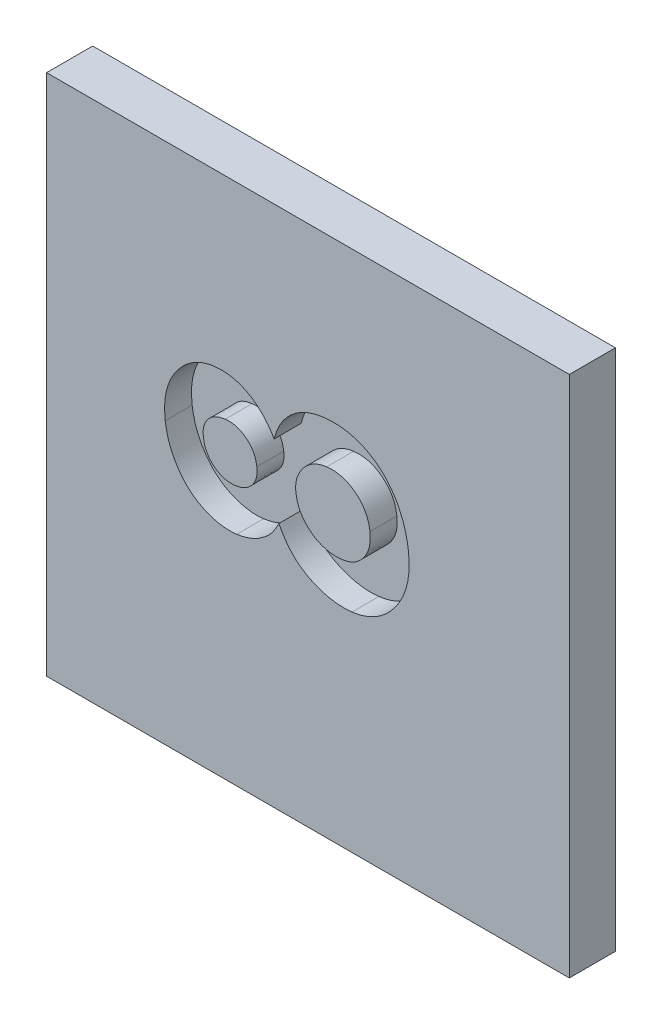
from build123d import *

# Parameters (mm, degrees)
SKIZZE1_W                       = 136
SKIZZE1_H                       = 136
AUFSATZ_LINEAR_AUSTRAGEN1_DEPTH = 12
SCHNITT_LINEAR_AUSTRAGEN2_DEPTH = 7


with BuildPart() as part:
    # Skizze1 → Aufsatz-Linear austragen1 (new body)
    with BuildSketch(Plane.XY):
        with Locations((18, -38)):
            Rectangle(SKIZZE1_W, SKIZZE1_H)
    extrude(amount=AUFSATZ_LINEAR_AUSTRAGEN1_DEPTH)

    # Skizze2 → Schnitt-Linear austragen2 (cut)
    with BuildSketch(Plane(origin=(31.817178146, 33.536064215, 12), x_dir=(-0.121869343, 0.992546152, 0), z_dir=(0, 0, 1))):
        with BuildLine():
            add(Edge.make_bspline(
                [(-53.274003062, 29.299786841), (-52.549854037, 28.997029862), (-51.129325688, 28.403126042), (-49.217358679, 27.153857855), (-47.540898563, 25.676342761), (-46.383253592, 24.230129356), (-45.579392411, 22.986547621), (-45.060203572, 21.996870887), (-44.632569988, 20.959918203), (-44.264434, 19.886493576), (-43.993212362, 18.762770223), (-43.787214797, 17.599258828), (-43.663882177, 16.389802125), (-43.652426375, 15.570103704), (-43.646599216, 15.153152225)],
                knots=[0, 0, 0, 0, 1.541464985, 3.0238178, 4.469784276, 5.921154489, 6.651437481, 7.38125241, 8.116115087, 8.856410813, 9.611538438, 10.387763072, 11.179912327, 12, 12, 12, 12], degree=3))
            add(Edge.make_bspline(
                [(-43.646599216, 15.153152225), (-43.650934028, 14.691984843), (-43.659509441, 13.779673016), (-43.806624249, 12.42868072), (-43.996415085, 11.108137934), (-44.308124238, 9.830927438), (-44.67636284, 8.587963111), (-45.135088006, 7.377098838), (-45.689116874, 6.208146216), (-46.311698148, 5.070923482), (-47.023881325, 3.99679881), (-47.791091102, 2.963169428), (-48.649851657, 2.008814583), (-49.564217558, 1.095396539), (-50.565090055, 0.262097691), (-51.626733483, -0.529779066), (-52.769329329, -1.242961105), (-53.9700016, -1.907524654), (-55.227178587, -2.493269476), (-56.533265143, -2.999356359), (-57.882028006, -3.431682546), (-59.277289658, -3.794809881), (-60.718920323, -4.070090999), (-62.204444332, -4.257904021), (-63.72850672, -4.385263221), (-64.760116786, -4.396473554), (-65.2812146, -4.402136236)],
                knots=[0, 0, 0, 0, 1.013897126, 2.005758377, 2.986752608, 3.946615008, 4.894629566, 5.837467942, 6.791608008, 7.738392708, 8.686857814, 9.624615693, 10.567330481, 11.508395868, 12.4653405, 13.429562997, 14.419856707, 15.425715908, 16.446941402, 17.468242957, 18.505094008, 19.561096764, 20.637967774, 21.731161366, 22.853940174, 24, 24, 24, 24], degree=3))
            add(Edge.make_bspline(
                [(-65.2812146, -4.402136236), (-65.958882909, -4.384472392), (-67.286063628, -4.349878605), (-69.234310849, -4.122595392), (-71.088778804, -3.725677952), (-72.855718687, -3.170705103), (-74.534480878, -2.458616989), (-76.126377078, -1.59186708), (-77.62546562, -0.565633337), (-79.007292948, 0.613232811), (-80.279643814, 1.880933964), (-81.37330296, 3.252409198), (-82.323408368, 4.667792163), (-83.081765939, 6.164635184), (-83.691564724, 7.71525695), (-84.107234052, 9.338475128), (-84.36939561, 11.017975802), (-84.400222214, 12.159382785), (-84.415829985, 12.737286841)],
                knots=[0, 0, 0, 0, 1.135997289, 2.224795934, 3.282557984, 4.310628835, 5.324785004, 6.334617724, 7.344294097, 8.364171613, 9.375722553, 10.350138575, 11.300131138, 12.228268618, 13.157450381, 14.08760252, 15.031736902, 16, 16, 16, 16], degree=3))
            add(Edge.make_bspline(
                [(-84.415829985, 12.737286841), (-84.398141873, 13.359514248), (-84.362560867, 14.611172777), (-84.046108264, 16.475278619), (-83.553289979, 18.332862908), (-82.85312214, 20.149856941), (-82.017226301, 21.902111555), (-81.027210856, 23.519078393), (-79.917924395, 24.982656379), (-78.672225452, 26.309139367), (-77.241589619, 27.499322426), (-75.614643729, 28.579625697), (-73.767611883, 29.54881074), (-72.437994582, 30.081084152), (-71.747560754, 30.357479148)],
                knots=[0, 0, 0, 0, 0.966358808, 1.943905445, 2.930138045, 3.948911318, 4.965341682, 5.943482994, 6.889898855, 7.81483236, 8.765090803, 9.775304409, 10.844776544, 12, 12, 12, 12], degree=3))
            add(Edge.make_bspline(
                [(-71.747560754, 30.357479148), (-72.190721524, 30.64916288), (-73.049869939, 31.21464528), (-74.198295254, 32.185447077), (-75.188865659, 33.212349202), (-75.711488475, 33.97567747), (-75.966310754, 34.347863764)],
                knots=[0, 0, 0, 0, 1.086599153, 2.106571708, 3.076795543, 4, 4, 4, 4], degree=3))
            add(Edge.make_bspline(
                [(-75.966310754, 34.347863764), (-76.323165999, 34.955072604), (-77.026932898, 36.152570718), (-77.722795567, 38.108141332), (-78.183557617, 40.123534227), (-78.235661796, 41.500702427), (-78.261983831, 42.196421456)],
                knots=[0, 0, 0, 0, 1.01806741, 2.007766889, 2.993561943, 4, 4, 4, 4], degree=3))
            add(Edge.make_bspline(
                [(-78.261983831, 42.196421456), (-78.23537461, 42.899971663), (-78.182076723, 44.309172574), (-77.713813486, 46.382422626), (-76.98599469, 48.408961783), (-75.963831699, 50.35796208), (-74.679088677, 52.192340379), (-73.1141166, 53.832767013), (-71.311800914, 55.27680529), (-69.26532957, 56.470788107), (-67.067165132, 57.465332003), (-64.736515258, 58.152022532), (-62.317145024, 58.593943299), (-60.671791448, 58.647564987), (-59.836503062, 58.674786841)],
                knots=[0, 0, 0, 0, 0.920470165, 1.843688453, 2.76992918, 3.734585969, 4.717327891, 5.693547554, 6.694185358, 7.731825961, 8.788908859, 9.846421484, 10.906703612, 12, 12, 12, 12], degree=3))
            add(Edge.make_bspline(
                [(-59.836503062, 58.674786841), (-59.230982927, 58.660259621), (-58.040482085, 58.63169795), (-56.29829286, 58.427393175), (-54.639261562, 58.081149502), (-53.069185983, 57.580466848), (-51.57240866, 56.964326646), (-50.17144743, 56.179926487), (-48.840427099, 55.284798301), (-47.625062234, 54.234512576), (-46.51940804, 53.108549537), (-45.544104678, 51.921381805), (-44.721799141, 50.677089491), (-44.047594914, 49.380403728), (-43.523480515, 48.029943504), (-43.154546402, 46.631027002), (-42.914252151, 45.181451885), (-42.889751129, 44.19657612), (-42.877368446, 43.698825302)],
                knots=[0, 0, 0, 0, 1.153096654, 2.26707992, 3.335605646, 4.375719133, 5.401714499, 6.412617512, 7.428490256, 8.451445124, 9.465855333, 10.431151224, 11.372908333, 12.301184165, 13.209487923, 14.12567389, 15.05272585, 16, 16, 16, 16], degree=3))
            add(Edge.make_bspline(
                [(-42.877368446, 43.698825302), (-42.905643962, 42.958950067), (-42.961586368, 41.495125281), (-43.463389482, 39.353175554), (-44.279012696, 37.308231587), (-45.223063581, 35.70248234), (-46.124653996, 34.47762788), (-46.898000859, 33.598462819), (-47.754048911, 32.766661016), (-48.698521395, 31.984937493), (-49.71790019, 31.242139238), (-50.818648115, 30.538084778), (-52.011488975, 29.891995585), (-52.847287007, 29.499946967), (-53.274003062, 29.299786841)],
                knots=[0, 0, 0, 0, 1.410602094, 2.790841224, 4.173979642, 5.599674553, 6.332295756, 7.074709729, 7.831826395, 8.608276812, 9.412839061, 10.238069433, 11.10044768, 12, 12, 12, 12], degree=3))
        make_face()
        with BuildLine():
            add(Edge.make_bspline(
                [(-59.824483831, 48.674786841), (-60.352516059, 48.652845307), (-61.377655752, 48.610247269), (-62.841578901, 48.176829263), (-64.179276715, 47.502792548), (-65.328034146, 46.544266315), (-66.298085013, 45.433090348), (-66.979481403, 44.156862114), (-67.428371825, 42.779160436), (-67.471044622, 41.81135706), (-67.492753062, 41.31901761)],
                knots=[0, 0, 0, 0, 1.068429257, 2.074284832, 3.070241312, 4.086972024, 5.090164471, 6.043007022, 7.004441531, 8, 8, 8, 8], degree=3))
            add(Edge.make_bspline(
                [(-67.492753062, 41.31901761), (-67.473929185, 40.864109489), (-67.437584116, 39.985774676), (-67.10130135, 38.732293616), (-66.555869581, 37.605825006), (-65.793957463, 36.626955052), (-64.85152003, 35.830710586), (-63.759665259, 35.234717657), (-62.512294914, 34.89677058), (-61.637404139, 34.851936614), (-61.182656908, 34.828632995)],
                knots=[0, 0, 0, 0, 1.072640992, 2.07105101, 3.040153855, 4.011148896, 4.977985479, 5.93481482, 6.926566298, 8, 8, 8, 8], degree=3))
            add(Edge.make_bspline(
                [(-61.182656908, 34.828632995), (-60.675198217, 34.852732592), (-59.683858844, 34.899812049), (-58.25660237, 35.309317711), (-56.964037268, 35.9996827), (-55.813856169, 36.92405734), (-54.852540828, 38.040749573), (-54.160091132, 39.316271312), (-53.708891249, 40.708196247), (-53.667713225, 41.684039252), (-53.646599216, 42.184402225)],
                knots=[0, 0, 0, 0, 1.037945009, 2.027664072, 3.011479609, 4.021405977, 5.034361915, 6.007613099, 6.978404693, 8, 8, 8, 8], degree=3))
            add(Edge.make_bspline(
                [(-53.646599216, 42.184402225), (-53.666798435, 42.658891111), (-53.705626475, 43.570979511), (-54.016462781, 44.86413864), (-54.553639658, 46.001166987), (-55.306058321, 46.957341882), (-56.231623271, 47.721425808), (-57.298628269, 48.291058685), (-58.519459621, 48.619028893), (-59.377778434, 48.655701083), (-59.824483831, 48.674786841)],
                knots=[0, 0, 0, 0, 1.125735341, 2.163949832, 3.13403846, 4.089322881, 5.028366283, 5.964514375, 6.940647228, 8, 8, 8, 8], degree=3))
        make_face(mode=Mode.SUBTRACT)
        with BuildLine():
            add(Edge.make_bspline(
                [(-63.189868446, 24.828632995), (-63.546958578, 24.819849725), (-64.248124359, 24.802603301), (-65.278687486, 24.65284738), (-66.26588341, 24.414922112), (-67.218030368, 24.074508741), (-68.124171376, 23.627691128), (-69.003132144, 23.096478873), (-69.826939518, 22.456502489), (-70.60548384, 21.735610071), (-71.325260982, 20.956120151), (-71.937654968, 20.102103173), (-72.475933951, 19.21637189), (-72.891806632, 18.266658625), (-73.23408407, 17.279544911), (-73.471791767, 16.239953845), (-73.620371311, 15.153463462), (-73.637753519, 14.412457228), (-73.646599216, 14.035363764)],
                knots=[0, 0, 0, 0, 1.022699828, 2.008126405, 2.97703308, 3.928371719, 4.898705406, 5.867340031, 6.866115651, 7.881574119, 8.905497311, 9.899710627, 10.88800813, 11.869414728, 12.86409184, 13.877666882, 14.919957873, 16, 16, 16, 16], degree=3))
            add(Edge.make_bspline(
                [(-73.646599216, 14.035363764), (-73.640730826, 13.742494084), (-73.629182877, 13.166178536), (-73.506274856, 12.319691722), (-73.299042285, 11.512101699), (-73.024438513, 10.736080079), (-72.661044756, 9.998176326), (-72.211928017, 9.301423414), (-71.69298417, 8.63354458), (-70.897386445, 7.811501758), (-69.765093278, 6.920074697), (-68.20602131, 6.153297916), (-66.48212127, 5.682850004), (-65.276239729, 5.626722634), (-64.6562146, 5.597863764)],
                knots=[0, 0, 0, 0, 0.765577671, 1.506520972, 2.230828579, 2.943445027, 3.655753251, 4.376641964, 5.10818981, 5.864097246, 7.364868711, 8.850381499, 10.380568448, 12, 12, 12, 12], degree=3))
            add(Edge.make_bspline(
                [(-64.6562146, 5.597863764), (-64.303276767, 5.60798212), (-63.606944844, 5.627945223), (-62.583729736, 5.759470932), (-61.600836455, 5.98873611), (-60.664613203, 6.315794911), (-59.766226508, 6.72225095), (-58.923393343, 7.236963036), (-58.111452735, 7.823213793), (-57.360485007, 8.510439488), (-56.670487949, 9.256542712), (-56.064396729, 10.052539505), (-55.557242701, 10.892031566), (-55.125912347, 11.768004638), (-54.829245921, 12.70010661), (-54.571654283, 13.654754893), (-54.446892724, 14.661094212), (-54.426319372, 15.345216002), (-54.415829985, 15.69401761)],
                knots=[0, 0, 0, 0, 1.056305773, 2.084048128, 3.08168982, 4.071445464, 5.04796526, 6.026838119, 7.02217112, 8.040920205, 9.067752774, 10.060626909, 11.029237137, 11.999997446, 12.974527425, 13.951709593, 14.95567281, 16, 16, 16, 16], degree=3))
            add(Edge.make_bspline(
                [(-54.415829985, 15.69401761), (-54.420212832, 16.011077436), (-54.428798095, 16.632144566), (-54.571380931, 17.540495533), (-54.778084438, 18.411484434), (-55.040943582, 19.254181447), (-55.431443296, 20.041285755), (-55.871685818, 20.803016633), (-56.400701962, 21.527217186), (-57.018595147, 22.18920949), (-57.663255138, 22.817132274), (-58.37114809, 23.341821526), (-59.092094086, 23.807956713), (-59.854804271, 24.181238548), (-60.648883729, 24.471086265), (-61.47193078, 24.670280394), (-62.319368408, 24.815697034), (-62.896756264, 24.824277236), (-63.189868446, 24.828632995)],
                knots=[0, 0, 0, 0, 1.079541345, 2.114640806, 3.124851578, 4.130993379, 5.114360147, 6.112033921, 7.128042352, 8.162330853, 9.195897967, 10.190014293, 11.159824633, 12.118612945, 13.077595717, 14.034729518, 15.002326226, 16, 16, 16, 16], degree=3))
        make_face(mode=Mode.SUBTRACT)
    extrude(amount=-SCHNITT_LINEAR_AUSTRAGEN2_DEPTH, mode=Mode.SUBTRACT)


solid = part.part
